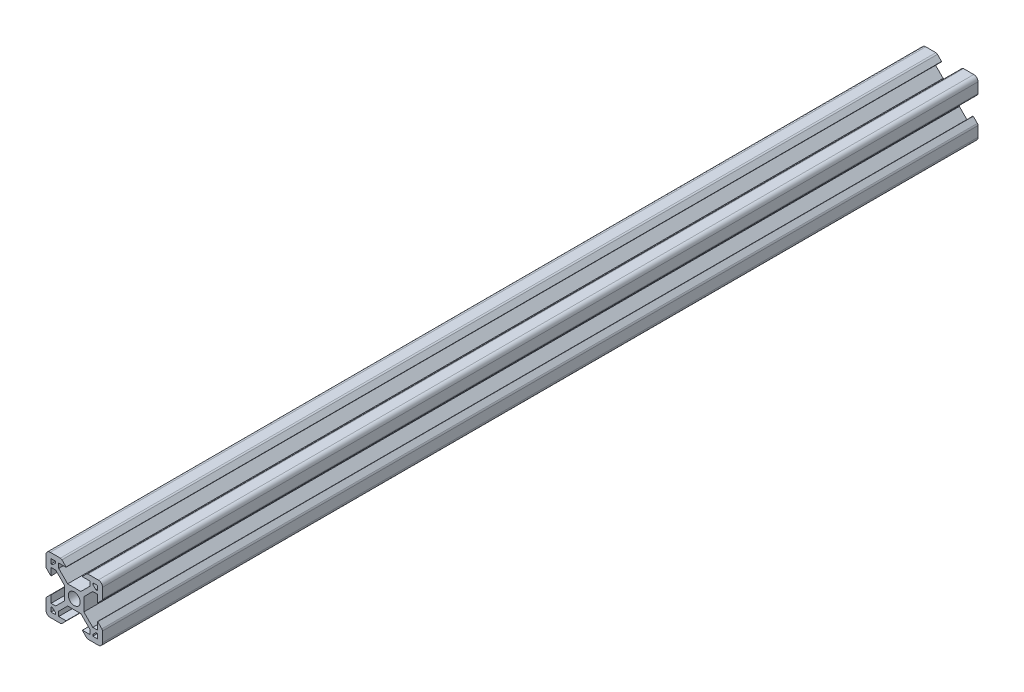
from build123d import *

# Parameters (mm, degrees)
SKETCH6_R           = 2.1
BOSS_EXTRUDE1_DEPTH = 310


with BuildPart() as part:
    # Sketch6 → Boss-Extrude1 (new body)
    with BuildSketch(Plane.XY):
        with BuildLine():
            Line((-3.4, -2.339339828), (-3.4, 2.339339828))
            Line((-3.4, 2.339339828), (-6.560660172, 5.5))
            Line((-6.560660172, 5.5), (-8.2, 5.5))
            Line((-8.2, 5.5), (-8.2, 2.89))
            Line((-8.2, 2.89), (-8.31, 2.89))
            Line((-8.31, 2.89), (-9.768614357, 4.348614357))
            ThreePointArc((-9.768614357, 4.348614357), (-9.939864831, 4.604908803), (-10, 4.907228714))
            Line((-10, 4.907228714), (-10, 8.5))
            ThreePointArc((-10, 8.5), (-9.560660172, 9.560660172), (-8.5, 10))
            Line((-8.5, 10), (-4.907228714, 10))
            ThreePointArc((-4.907228714, 10), (-4.604908803, 9.939864831), (-4.348614357, 9.768614357))
            Line((-4.348614357, 9.768614357), (-2.89, 8.31))
            Line((-2.89, 8.31), (-2.89, 8.2))
            Line((-2.89, 8.2), (-5.5, 8.2))
            Line((-5.5, 8.2), (-5.5, 6.560660172))
            Line((-5.5, 6.560660172), (-2.339339828, 3.4))
            Line((-2.339339828, 3.4), (2.339339828, 3.4))
            Line((2.339339828, 3.4), (5.5, 6.560660172))
            Line((5.5, 6.560660172), (5.5, 8.2))
            Line((5.5, 8.2), (2.89, 8.2))
            Line((2.89, 8.2), (2.89, 8.31))
            Line((2.89, 8.31), (4.348614357, 9.768614357))
            ThreePointArc((4.348614357, 9.768614357), (4.604908803, 9.939864831), (4.907228714, 10))
            Line((4.907228714, 10), (8.5, 10))
            ThreePointArc((8.5, 10), (9.560660172, 9.560660172), (10, 8.5))
            Line((10, 8.5), (10, 4.907228714))
            ThreePointArc((10, 4.907228714), (9.939864831, 4.604908803), (9.768614357, 4.348614357))
            Line((9.768614357, 4.348614357), (8.31, 2.89))
            Line((8.31, 2.89), (8.2, 2.89))
            Line((8.2, 2.89), (8.2, 5.5))
            Line((8.2, 5.5), (6.560660172, 5.5))
            Line((6.560660172, 5.5), (3.4, 2.339339828))
            Line((3.4, 2.339339828), (3.4, -2.339339828))
            Line((3.4, -2.339339828), (6.560660172, -5.5))
            Line((6.560660172, -5.5), (8.2, -5.5))
            Line((8.2, -5.5), (8.2, -2.89))
            Line((8.2, -2.89), (8.31, -2.89))
            Line((8.31, -2.89), (9.768614357, -4.348614357))
            ThreePointArc((9.768614357, -4.348614357), (9.939864831, -4.604908803), (10, -4.907228714))
            Line((10, -4.907228714), (10, -8.5))
            ThreePointArc((10, -8.5), (9.560660172, -9.560660172), (8.5, -10))
            Line((8.5, -10), (4.907228714, -10))
            ThreePointArc((4.907228714, -10), (4.604908803, -9.939864831), (4.348614357, -9.768614357))
            Line((4.348614357, -9.768614357), (2.89, -8.31))
            Line((2.89, -8.31), (2.89, -8.2))
            Line((2.89, -8.2), (5.5, -8.2))
            Line((5.5, -8.2), (5.5, -6.560660172))
            Line((5.5, -6.560660172), (2.339339828, -3.4))
            Line((2.339339828, -3.4), (-2.339339828, -3.4))
            Line((-2.339339828, -3.4), (-5.5, -6.560660172))
            Line((-5.5, -6.560660172), (-5.5, -8.2))
            Line((-5.5, -8.2), (-2.89, -8.2))
            Line((-2.89, -8.2), (-2.89, -8.31))
            Line((-2.89, -8.31), (-4.348614357, -9.768614357))
            ThreePointArc((-4.348614357, -9.768614357), (-4.604908803, -9.939864831), (-4.907228714, -10))
            Line((-4.907228714, -10), (-8.5, -10))
            ThreePointArc((-8.5, -10), (-9.560660172, -9.560660172), (-10, -8.5))
            Line((-10, -8.5), (-10, -4.907228714))
            ThreePointArc((-10, -4.907228714), (-9.939864831, -4.604908803), (-9.768614357, -4.348614357))
            Line((-9.768614357, -4.348614357), (-8.31, -2.89))
            Line((-8.31, -2.89), (-8.2, -2.89))
            Line((-8.2, -2.89), (-8.2, -5.5))
            Line((-8.2, -5.5), (-6.560660172, -5.5))
            Line((-6.560660172, -5.5), (-3.4, -2.339339828))
        make_face()
        Circle(SKETCH6_R, mode=Mode.SUBTRACT)
        Polygon((-7.66, 6.57), (-6.57, 7.66), (-6.57, 8.2), (-8.2, 8.2), (-8.2, 6.57), align=None, mode=Mode.SUBTRACT)
        Polygon((8.2, 6.57), (7.66, 6.57), (6.57, 7.66), (6.57, 8.2), (8.2, 8.2), align=None, mode=Mode.SUBTRACT)
        Polygon((7.66, -6.57), (6.57, -7.66), (6.57, -8.2), (8.2, -8.2), (8.2, -6.57), align=None, mode=Mode.SUBTRACT)
        Polygon((-8.2, -6.57), (-7.66, -6.57), (-6.57, -7.66), (-6.57, -8.2), (-8.2, -8.2), align=None, mode=Mode.SUBTRACT)
    extrude(amount=-BOSS_EXTRUDE1_DEPTH)


solid = part.part
